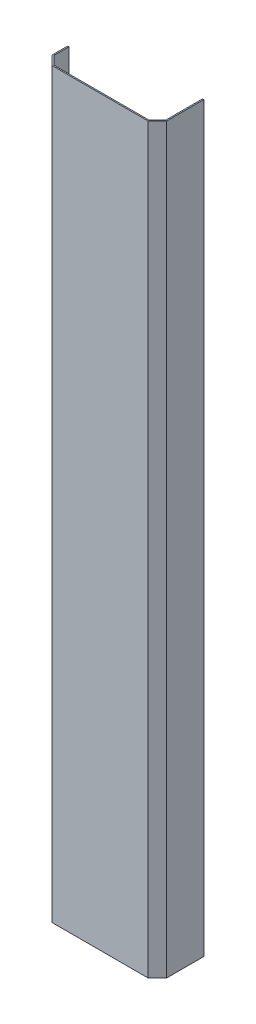
from build123d import *

# Parameters (mm, degrees)
BOSS_EXTRUDE1_DEPTH = 1200


with BuildPart() as part:
    # Sketch1 → Boss-Extrude1 (new body)
    with BuildSketch(Plane(origin=(0, 0, 0), x_dir=(1, 0, 0), z_dir=(0, 1, 0))):
        Polygon((15.828427125, 2), (2, 15.828427125), (2, 40), (0, 40), (0, 15), (15, 0), (170, 0), (185, 15), (185, 75), (183, 75), (183, 15.828427125), (169.171572875, 2), align=None)
    extrude(amount=BOSS_EXTRUDE1_DEPTH)


solid = part.part
